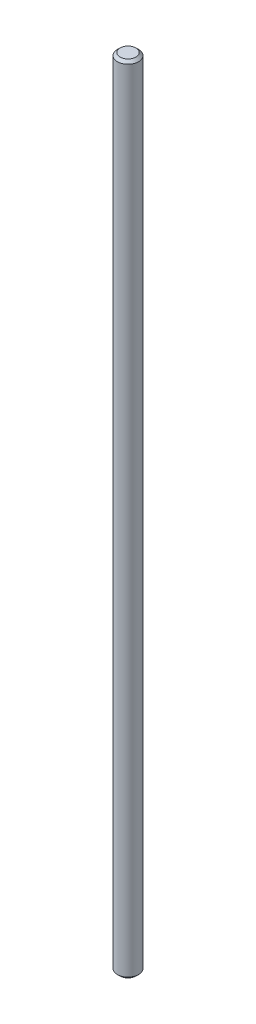
from build123d import *

# Parameters (mm, degrees)
SKETCH1_R           = 4
BOSS_EXTRUDE1_DEPTH = 300
CHAMFER1_SIZE       = 1


with BuildPart() as part:
    # Sketch1 → Boss-Extrude1 (new body)
    with BuildSketch(Plane(origin=(0, 0, 0), x_dir=(1, 0, 0), z_dir=(0, 1, 0))):
        Circle(SKETCH1_R)
    extrude(amount=BOSS_EXTRUDE1_DEPTH)

    # Chamfer1
    chamfer1_edges = [part.edges().sort_by_distance(p)[0] for p in [
        (-4, 0, 0),
        (-4, 300, 0),
    ]]
    chamfer(chamfer1_edges, length=CHAMFER1_SIZE)


solid = part.part
